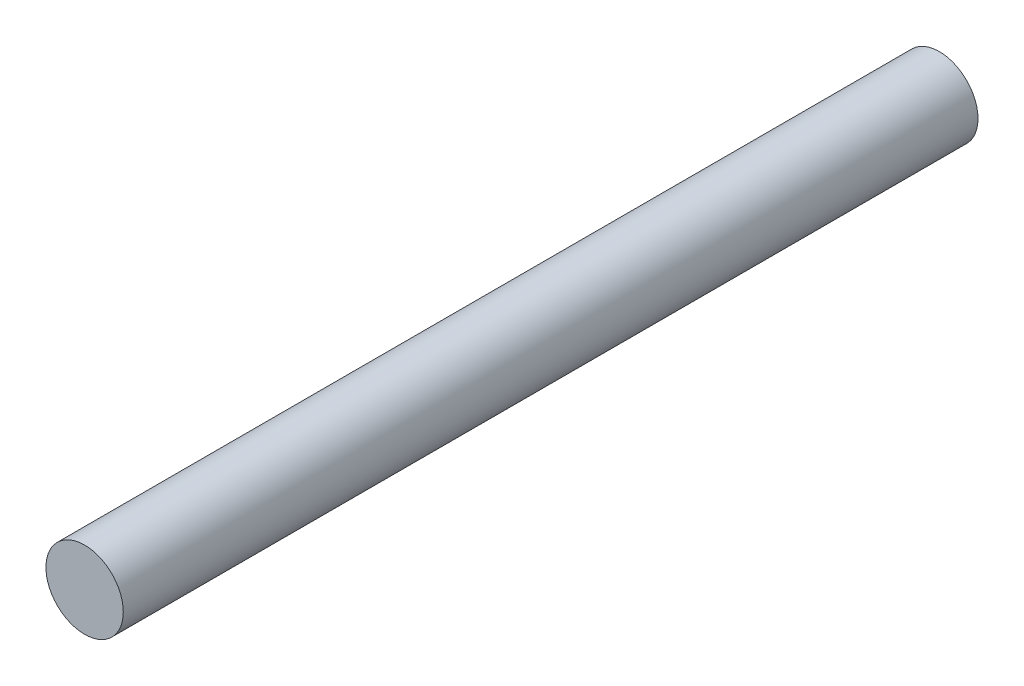
from build123d import *

# Parameters (mm, degrees)
SKETCH1_R           = 3
BOSS_EXTRUDE1_DEPTH = 66.3


with BuildPart() as part:
    # Sketch1 → Boss-Extrude1 (new body)
    with BuildSketch(Plane.XY):
        Circle(SKETCH1_R)
    extrude(amount=BOSS_EXTRUDE1_DEPTH)


solid = part.part
